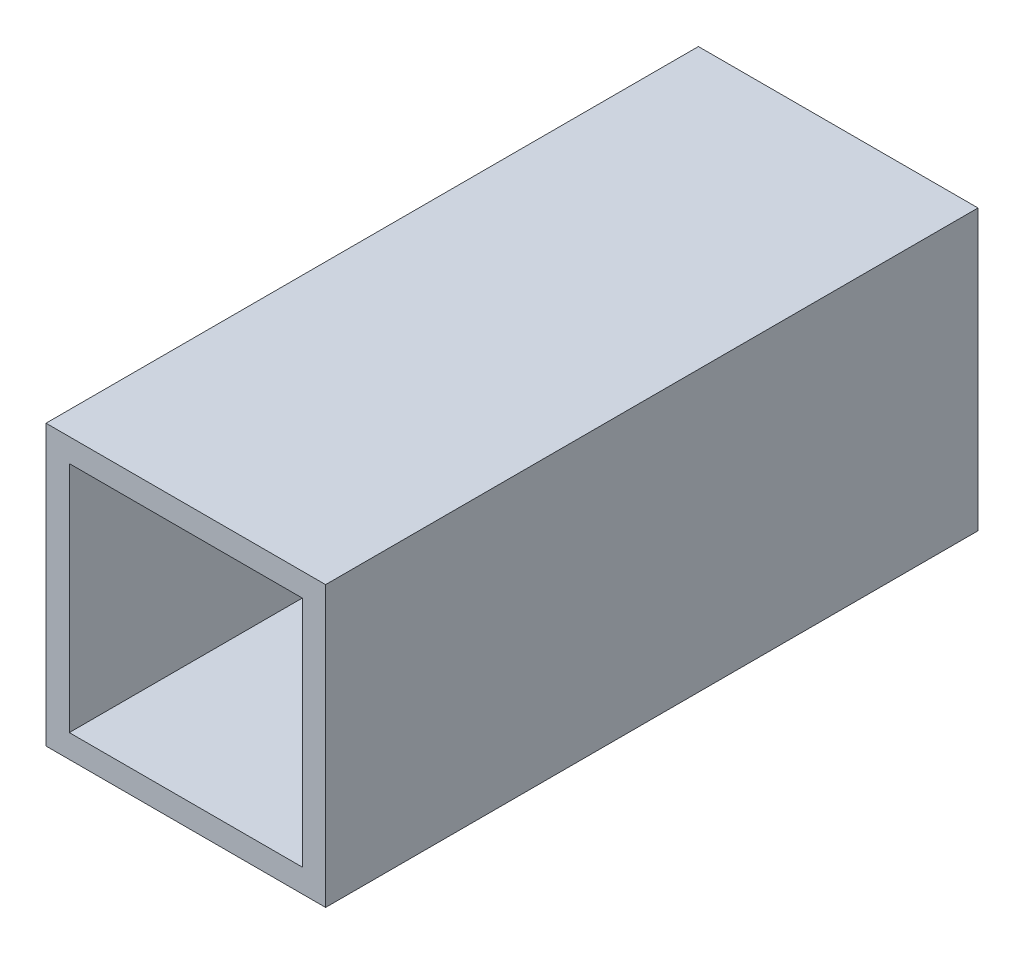
from build123d import *

# Parameters (mm, degrees)
CROQUIS1_W              = 19.05
CROQUIS1_H              = 19.05
CROQUIS1_W_2            = 15.875
CROQUIS1_H_2            = 15.875
SALIENTE_EXTRUIR1_DEPTH = 22.225


with BuildPart() as part:
    # Croquis1 → Saliente-Extruir1 (new body, symmetric)
    with BuildSketch(Plane.XY):
        Rectangle(CROQUIS1_W, CROQUIS1_H)
        Rectangle(CROQUIS1_W_2, CROQUIS1_H_2, mode=Mode.SUBTRACT)
    extrude(amount=SALIENTE_EXTRUIR1_DEPTH, both=True)


solid = part.part
